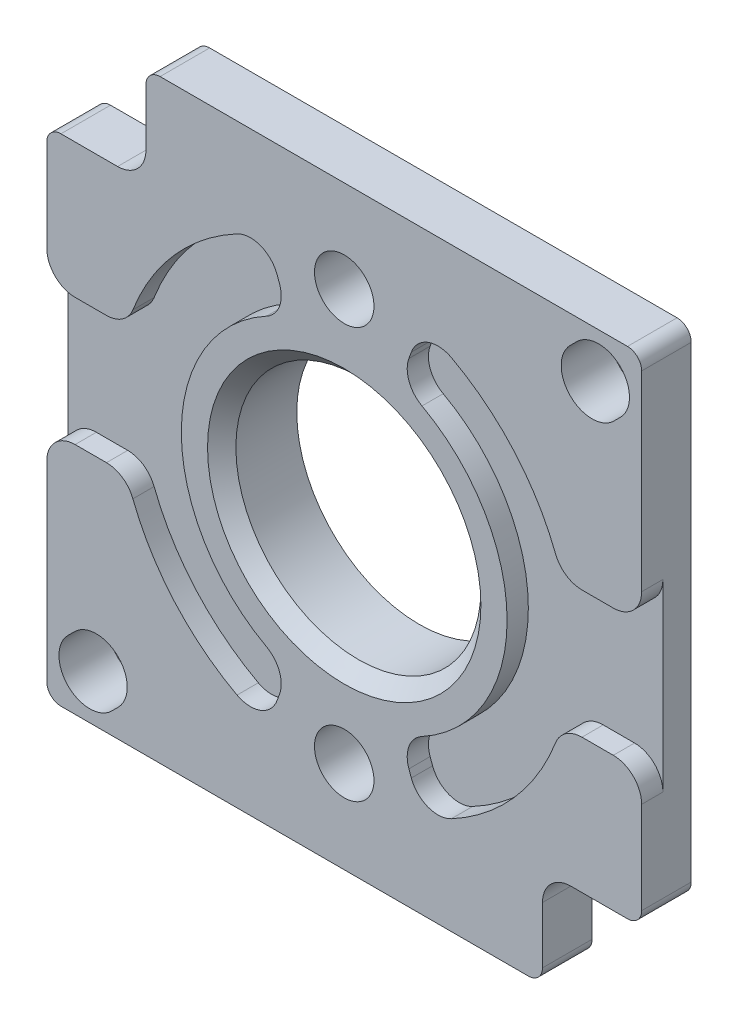
from build123d import *

# Parameters (mm, degrees)
SKETCH1_W                      = 42
SKETCH1_H                      = 42
BOSS_EXTRUDE1_DEPTH            = 3.5
CUT_EXTRUDE1_DEPTH             = 1.5
CUT_EXTRUDE2_DEPTH             = 1.5
SKETCH4_W                      = 7
SKETCH4_H                      = 7
CUT_EXTRUDE3_DEPTH             = 4.5
SKETCH5_W                      = 7
SKETCH5_H                      = 7
CUT_EXTRUDE4_DEPTH             = 4.5
CUT_EXTRUDE5_DEPTH             = 4.5
CUT_EXTRUDE6_DEPTH             = 4.5
BOSS_EXTRUDE2_DEPTH            = 1.8
CUT_EXTRUDE7_DEPTH             = 1.8
CUT_EXTRUDE8_DEPTH             = 1.8
CUT_EXTRUDE9_DEPTH             = 1.8
CUT_EXTRUDE10_DEPTH            = 1.8
CUT_EXTRUDE11_DEPTH            = 1.8
CUT_EXTRUDE12_DEPTH            = 1.8
F_4_2_4_2_DIAMETER_HOLE1_D     = 4.2
F_4_2_4_2_DIAMETER_HOLE1_DEPTH = 5.3
M16_CLEARANCE_HOLE1_D          = 17.3
M16_CLEARANCE_HOLE1_DEPTH      = 5.3
FILLET1_R                      = 1
CHAMFER1_SIZE                  = 0.5
CHAMFER2_SIZE                  = 1
FILLET2_R                      = 2


with BuildPart() as part:
    # Sketch1 → Boss-Extrude1 (new body)
    with BuildSketch(Plane.XY.offset(1.75)):
        Rectangle(SKETCH1_W, SKETCH1_H)
    extrude(amount=-BOSS_EXTRUDE1_DEPTH)

    # Sketch2 → Cut-Extrude1 (cut)
    with BuildSketch(Plane.XY.offset(1.75)):
        with BuildLine():
            Line((21, 4.5), (15.354152533, 4.5))
            ThreePointArc((15.354152533, 4.5), (11.669725843, 10.946117976), (5.472322293, 15.035081933))
            Line((5.472322293, 15.035081933), (3.933231648, 10.806465139))
            ThreePointArc((3.933231648, 10.806465139), (11.5, 0), (3.933231648, -10.806465139))
            Line((3.933231648, -10.806465139), (5.472322293, -15.035081933))
            ThreePointArc((5.472322293, -15.035081933), (11.669725843, -10.946117976), (15.354152533, -4.5))
            Line((15.354152533, -4.5), (21, -4.5))
            Line((21, -4.5), (21, 4.5))
        make_face()
    extrude(amount=-CUT_EXTRUDE1_DEPTH, mode=Mode.SUBTRACT)

    # Sketch3 → Cut-Extrude2 (cut)
    with BuildSketch(Plane.XY.offset(1.75)):
        with BuildLine():
            Line((-21, -4.5), (-15.354152533, -4.5))
            ThreePointArc((-15.354152533, -4.5), (-11.669725843, -10.946117976), (-5.472322293, -15.035081933))
            Line((-5.472322293, -15.035081933), (-3.933231648, -10.806465139))
            ThreePointArc((-3.933231648, -10.806465139), (-11.5, 0), (-3.933231648, 10.806465139))
            Line((-3.933231648, 10.806465139), (-5.472322293, 15.035081933))
            ThreePointArc((-5.472322293, 15.035081933), (-11.669725843, 10.946117976), (-15.354152533, 4.5))
            Line((-15.354152533, 4.5), (-21, 4.5))
            Line((-21, 4.5), (-21, -4.5))
        make_face()
    extrude(amount=-CUT_EXTRUDE2_DEPTH, mode=Mode.SUBTRACT)

    # Sketch4 → Cut-Extrude3 (cut, through all)
    with BuildSketch(Plane(origin=(0, 0, -1.75), x_dir=(-1, 0, 0), z_dir=(0, 0, -1))):
        with Locations((-17.5, -17.5)):
            Rectangle(SKETCH4_W, SKETCH4_H)
    extrude(amount=-CUT_EXTRUDE3_DEPTH, mode=Mode.SUBTRACT)

    # Sketch5 → Cut-Extrude4 (cut, through all)
    with BuildSketch(Plane(origin=(0, 0, -1.75), x_dir=(-1, 0, 0), z_dir=(0, 0, -1))):
        with Locations((17.5, 17.5)):
            Rectangle(SKETCH5_W, SKETCH5_H)
    extrude(amount=-CUT_EXTRUDE4_DEPTH, mode=Mode.SUBTRACT)

    # Sketch6 → Cut-Extrude5 (cut, through all)
    with BuildSketch(Plane.XY.offset(1.75)):
        with BuildLine():
            Line((19.041492783, 15.958507217), (19.502005025, 16.419019459))
            ThreePointArc((19.502005025, 16.419019459), (19.502005025, 19.502005025), (16.419019459, 19.502005025))
            Line((16.419019459, 19.502005025), (15.958507217, 19.041492783))
            ThreePointArc((15.958507217, 19.041492783), (15.958507217, 15.958507217), (19.041492783, 15.958507217))
        make_face()
    extrude(amount=-CUT_EXTRUDE5_DEPTH, mode=Mode.SUBTRACT)

    # Sketch7 → Cut-Extrude6 (cut, through all)
    with BuildSketch(Plane(origin=(0, 0, -1.75), x_dir=(-1, 0, 0), z_dir=(0, 0, -1))):
        with BuildLine():
            Line((19.502005025, -16.419019459), (19.041492783, -15.958507217))
            ThreePointArc((19.041492783, -15.958507217), (15.958507217, -15.958507217), (15.958507217, -19.041492783))
            Line((15.958507217, -19.041492783), (16.419019459, -19.502005025))
            ThreePointArc((16.419019459, -19.502005025), (19.502005025, -19.502005025), (19.502005025, -16.419019459))
        make_face()
    extrude(amount=-CUT_EXTRUDE6_DEPTH, mode=Mode.SUBTRACT)

    # Sketch8 → Boss-Extrude2 (add)
    with BuildSketch(Plane(origin=(0, 0, -1.75), x_dir=(-1, 0, 0), z_dir=(0, 0, -1))):
        with BuildLine():
            ThreePointArc((-3.749159397, -14.420603448), (-14.9, 0), (-3.749159397, 14.420603448))
            ThreePointArc((-3.749159397, 14.420603448), (0, 10.75), (3.749159397, 14.420603448))
            ThreePointArc((3.749159397, 14.420603448), (14.9, 0), (3.749159397, -14.420603448))
            ThreePointArc((3.749159397, -14.420603448), (0, -10.75), (-3.749159397, -14.420603448))
        make_face()
    extrude(amount=BOSS_EXTRUDE2_DEPTH)

    # Sketch9 → Cut-Extrude7 (cut)
    with BuildSketch(Plane(origin=(0, 0, -3.55), x_dir=(-1, 0, 0), z_dir=(0, 0, -1))):
        with BuildLine():
            Line((12.180022738, -5.586326708), (9.174650801, -4.341460892))
            ThreePointArc((9.174650801, -4.341460892), (7.090577301, -7.262658848), (4.120254088, -9.276098655))
            ThreePointArc((4.120254088, -9.276098655), (3.545323076, -9.99532285), (3.801999979, -10.8796))
            ThreePointArc((3.801999979, -10.8796), (4.400674664, -11.637036064), (4.850525395, -12.491293103))
            ThreePointArc((4.850525395, -12.491293103), (9.188554438, -9.753484882), (12.180022738, -5.586326708))
        make_face()
    extrude(amount=-CUT_EXTRUDE7_DEPTH, mode=Mode.SUBTRACT)

    # Sketch10 → Cut-Extrude8 (cut)
    with BuildSketch(Plane(origin=(0, 0, -3.55), x_dir=(-1, 0, 0), z_dir=(0, 0, -1))):
        with BuildLine():
            Line((-9.174650801, -4.341460892), (-12.180022738, -5.586326708))
            ThreePointArc((-12.180022738, -5.586326708), (-9.188554438, -9.753484882), (-4.850525395, -12.491293103))
            ThreePointArc((-4.850525395, -12.491293103), (-4.400674664, -11.637036064), (-3.801999979, -10.8796))
            ThreePointArc((-3.801999979, -10.8796), (-3.545323076, -9.99532285), (-4.120254088, -9.276098655))
            ThreePointArc((-4.120254088, -9.276098655), (-7.090577301, -7.262658848), (-9.174650801, -4.341460892))
        make_face()
    extrude(amount=-CUT_EXTRUDE8_DEPTH, mode=Mode.SUBTRACT)

    # Sketch11 → Cut-Extrude9 (cut)
    with BuildSketch(Plane(origin=(0, 0, -3.55), x_dir=(-1, 0, 0), z_dir=(0, 0, -1))):
        with BuildLine():
            Line((-12.180022738, 5.586326708), (-9.174650801, 4.341460892))
            ThreePointArc((-9.174650801, 4.341460892), (-7.090577301, 7.262658848), (-4.120254088, 9.276098655))
            ThreePointArc((-4.120254088, 9.276098655), (-3.545323076, 9.99532285), (-3.801999979, 10.8796))
            ThreePointArc((-3.801999979, 10.8796), (-4.400674664, 11.637036064), (-4.850525395, 12.491293103))
            ThreePointArc((-4.850525395, 12.491293103), (-9.188554438, 9.753484882), (-12.180022738, 5.586326708))
        make_face()
    extrude(amount=-CUT_EXTRUDE9_DEPTH, mode=Mode.SUBTRACT)

    # Sketch12 → Cut-Extrude10 (cut)
    with BuildSketch(Plane(origin=(0, 0, -3.55), x_dir=(-1, 0, 0), z_dir=(0, 0, -1))):
        with BuildLine():
            Line((9.174650801, 4.341460892), (12.180022738, 5.586326708))
            ThreePointArc((12.180022738, 5.586326708), (9.188554438, 9.753484882), (4.850525395, 12.491293103))
            ThreePointArc((4.850525395, 12.491293103), (4.400674664, 11.637036064), (3.801999979, 10.8796))
            ThreePointArc((3.801999979, 10.8796), (3.545323076, 9.99532285), (4.120254088, 9.276098655))
            ThreePointArc((4.120254088, 9.276098655), (7.090577301, 7.262658848), (9.174650801, 4.341460892))
        make_face()
    extrude(amount=-CUT_EXTRUDE10_DEPTH, mode=Mode.SUBTRACT)

    # Sketch13 → Cut-Extrude11 (cut)
    with BuildSketch(Plane(origin=(0, 0, -3.55), x_dir=(-1, 0, 0), z_dir=(0, 0, -1))):
        with BuildLine():
            Line((9.557334234, -3.41758136), (12.562706171, -4.662447176))
            ThreePointArc((12.562706171, -4.662447176), (13.4, 0), (12.562706171, 4.662447176))
            Line((12.562706171, 4.662447176), (9.557334234, 3.41758136))
            ThreePointArc((9.557334234, 3.41758136), (10.15, 0), (9.557334234, -3.41758136))
        make_face()
    extrude(amount=-CUT_EXTRUDE11_DEPTH, mode=Mode.SUBTRACT)

    # Sketch14 → Cut-Extrude12 (cut)
    with BuildSketch(Plane(origin=(0, 0, -3.55), x_dir=(-1, 0, 0), z_dir=(0, 0, -1))):
        with BuildLine():
            Line((-12.562706171, -4.662447176), (-9.557334234, -3.41758136))
            ThreePointArc((-9.557334234, -3.41758136), (-10.15, 0), (-9.557334234, 3.41758136))
            Line((-9.557334234, 3.41758136), (-12.562706171, 4.662447176))
            ThreePointArc((-12.562706171, 4.662447176), (-13.4, 0), (-12.562706171, -4.662447176))
        make_face()
    extrude(amount=-CUT_EXTRUDE12_DEPTH, mode=Mode.SUBTRACT)

    # Ø4.2 (4.2) Diameter Hole1
    with Locations(Plane.XY.offset(1.75)):
        with Locations((0, 14.5), (0, -14.5)):
            Hole(F_4_2_4_2_DIAMETER_HOLE1_D / 2, depth=F_4_2_4_2_DIAMETER_HOLE1_DEPTH)

    # M16 Clearance Hole1
    with Locations(Plane.XY.offset(1.75)):
        with Locations((0, 0)):
            Hole(M16_CLEARANCE_HOLE1_D / 2, depth=M16_CLEARANCE_HOLE1_DEPTH)

    # Fillet1
    fillet1_edges = [part.edges().sort_by_distance(p)[0] for p in [
        (3.749159397, -14.420603448, -2.65),
        (-3.749159397, -14.420603448, -2.65),
        (-3.749159397, 14.420603448, -2.65),
        (3.749159397, 14.420603448, -2.65),
        (-4.850525395, -12.491293103, -2.65),
        (-9.174650801, -4.341460892, -2.65),
        (-12.180022738, -5.586326708, -2.65),
        (9.174650801, -4.341460892, -2.65),
        (4.850525395, -12.491293103, -2.65),
        (12.180022738, -5.586326708, -2.65),
        (4.850525395, 12.491293103, -2.65),
        (9.174650801, 4.341460892, -2.65),
        (12.180022738, 5.586326708, -2.65),
        (-4.850525395, 12.491293103, -2.65),
        (-12.180022738, 5.586326708, -2.65),
        (-9.174650801, 4.341460892, -2.65),
        (-9.557334234, -3.41758136, -2.65),
        (-9.557334234, 3.41758136, -2.65),
        (-12.562706171, 4.662447176, -2.65),
        (-12.562706171, -4.662447176, -2.65),
        (12.562706171, -4.662447176, -2.65),
        (12.562706171, 4.662447176, -2.65),
        (9.557334234, 3.41758136, -2.65),
        (9.557334234, -3.41758136, -2.65),
        (14, -21, 0),
        (21, -14, 0),
        (21, 21, 0),
        (-21, -21, 0),
        (-14, 21, 0),
        (-21, 14, 0),
    ]]
    fillet(fillet1_edges, radius=FILLET1_R)

    # Chamfer1
    chamfer1_edges = [part.edges().sort_by_distance(p)[0] for p in [
        (-14.9, 0, -3.55),
        (0, -10.75, -3.55),
        (0, 10.75, -3.55),
        (14.9, 0, -3.55),
        (-4.094020791, 14.024661136, -3.55),
        (4.094020791, -14.024661136, -3.55),
        (4.094020791, 14.024661136, -3.55),
        (-4.094020791, -14.024661136, -3.55),
    ]]
    chamfer(chamfer1_edges, length=CHAMFER1_SIZE)

    # Chamfer2
    chamfer2_edges = [part.edges().sort_by_distance(p)[0] for p in [
        (8.65, 0, 1.75),
    ]]
    chamfer(chamfer2_edges, length=CHAMFER2_SIZE)

    # Fillet2
    fillet2_edges = [part.edges().sort_by_distance(p)[0] for p in [
        (21, 4.5, 1),
        (21, -4.5, 1),
        (15.354152533, -4.5, 1),
        (5.472322293, -15.035081933, 1),
        (3.933231648, -10.806465139, 1),
        (3.933231648, 10.806465139, 1),
        (5.472322293, 15.035081933, 1),
        (15.354152533, 4.5, 1),
        (-21, -4.5, 1),
        (-21, 4.5, 1),
        (-15.354152533, 4.5, 1),
        (-5.472322293, 15.035081933, 1),
        (-3.933231648, 10.806465139, 1),
        (-3.933231648, -10.806465139, 1),
        (-5.472322293, -15.035081933, 1),
        (-15.354152533, -4.5, 1),
        (14, -14, 0),
        (-14, 14, 0),
    ]]
    fillet(fillet2_edges, radius=FILLET2_R)


solid = part.part
